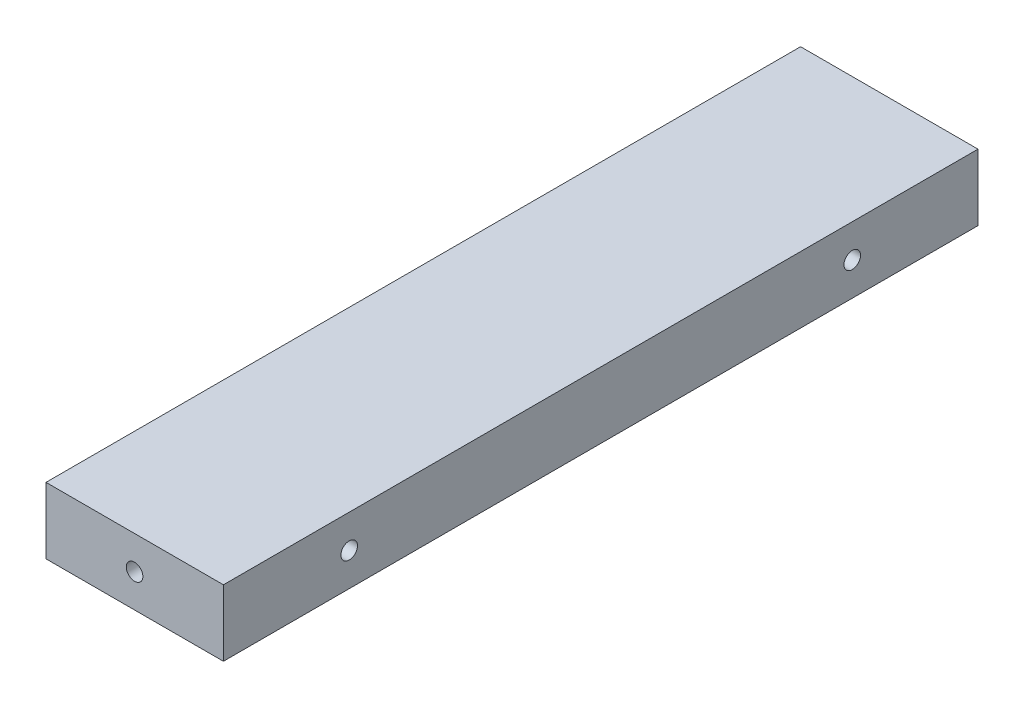
from build123d import *

# Parameters (mm, degrees)
SKETCH1_W           = 34
SKETCH1_H           = 12.7
BOSS_EXTRUDE1_DEPTH = 144.6
HOLE1_D             = 3.175
HOLE1_DEPTH         = 31.75
HOLE1_CSINK_D       = 10.16
HOLE1_CSINK_ANGLE   = 82
HOLE1_TIP           = 0.953866233
HOLE2_D             = 3.175
HOLE2_DEPTH         = 31.75
HOLE2_CSINK_D       = 10.16
HOLE2_CSINK_ANGLE   = 82
HOLE2_TIP           = 0.953866233
HOLE5_D             = 3.175
HOLE5_DEPTH         = 31.75
HOLE5_CSINK_D       = 10.16
HOLE5_CSINK_ANGLE   = 82
HOLE5_TIP           = 0.953866233
HOLE6_D             = 3.175
HOLE6_DEPTH         = 31.75
HOLE6_CSINK_D       = 10.16
HOLE6_CSINK_ANGLE   = 82
HOLE6_TIP           = 0.953866233
HOLE7_D             = 3.175
HOLE7_DEPTH         = 31.75
HOLE7_CSINK_D       = 10.16
HOLE7_CSINK_ANGLE   = 82
HOLE7_TIP           = 0.953866233


with BuildPart() as part:
    # Sketch1 → Boss-Extrude1 (new body)
    with BuildSketch(Plane.XY):
        with Locations((-23.08092085, -126.349999994)):
            Rectangle(SKETCH1_W, SKETCH1_H)
    extrude(amount=BOSS_EXTRUDE1_DEPTH)

    # Hole1
    with Locations(Plane(origin=(12.91907915, 0, 155.024290059), x_dir=(0, -1, 0), z_dir=(1, 0, 0))):
        with Locations((126.349999994, 161.374290059), (146.083333327, 4.074290059), (172.166666661, 4.074290059), (126.349999994, 34.524290059), (126.349999994, 130.924290059), (-172.166666661, 4.074290059), (-146.083333327, 4.074290059), (-126.349999994, 34.524290059), (-126.349999994, 130.924290059), (-126.349999994, 161.374290059)):
            CounterSinkHole(HOLE1_D / 2, HOLE1_CSINK_D / 2, depth=HOLE1_DEPTH, counter_sink_angle=HOLE1_CSINK_ANGLE)
            with Locations((0, 0, -(HOLE1_DEPTH + HOLE1_TIP / 2))):  # 118° drill point
                Cone(0, HOLE1_D / 2, HOLE1_TIP, mode=Mode.SUBTRACT)

    # Hole2
    with Locations(Plane(origin=(12.91907915, 0, -10.424290059), x_dir=(0, 1, 0), z_dir=(1, 0, 0))):
        with Locations((126.349999994, 161.374290059), (146.083333327, 4.074290059), (172.166666661, 4.074290059), (126.349999994, 34.524290059), (126.349999994, 130.924290059), (-172.166666661, 4.074290059), (-146.083333327, 4.074290059), (-126.349999994, 34.524290059), (-126.349999994, 130.924290059), (-126.349999994, 161.374290059)):
            CounterSinkHole(HOLE2_D / 2, HOLE2_CSINK_D / 2, depth=HOLE2_DEPTH, counter_sink_angle=HOLE2_CSINK_ANGLE)
            with Locations((0, 0, -(HOLE2_DEPTH + HOLE2_TIP / 2))):  # 118° drill point
                Cone(0, HOLE2_D / 2, HOLE2_TIP, mode=Mode.SUBTRACT)

    # Hole5
    with Locations(Plane(origin=(-195.367659426, 0, 157.3), x_dir=(0, -1, 0), z_dir=(0, 0, 1))):
        with Locations((207.774999994, 172.261738577), (126.349999994, 172.261738577)):
            CounterSinkHole(HOLE5_D / 2, HOLE5_CSINK_D / 2, depth=HOLE5_DEPTH, counter_sink_angle=HOLE5_CSINK_ANGLE)
            with Locations((0, 0, -(HOLE5_DEPTH + HOLE5_TIP / 2))):  # 118° drill point
                Cone(0, HOLE5_D / 2, HOLE5_TIP, mode=Mode.SUBTRACT)

    # Hole6
    with Locations(Plane(origin=(-52.78092085, 0, -10.424290059), x_dir=(0, -1, 0), z_dir=(-1, 0, 0))):
        with Locations((-207.774999994, 333.02141023), (-207.774999994, 225.48903684), (-207.774999994, 137.424290059), (-172.166666661, 4.074290059), (-146.083333327, 4.074290059), (-94.599999994, 161.374290059), (0, 161.374290059), (94.599999994, 161.374290059), (146.083333327, 4.074290059), (172.166666661, 4.074290059), (207.774999994, 137.424290059), (207.774999994, 225.48903684), (207.774999994, 333.02141023), (166.795833328, 301.970350905), (40.979166666, 301.970350905), (-40.979166666, 301.970350905), (-166.795833328, 301.970350905), (0, 193.124290059), (0, 301.970350905), (0, 412.366411751), (-126.349999994, 106.824290059), (-126.349999994, 58.624290059), (126.349999994, 58.624290059), (126.349999994, 106.824290059)):
            CounterSinkHole(HOLE6_D / 2, HOLE6_CSINK_D / 2, depth=HOLE6_DEPTH, counter_sink_angle=HOLE6_CSINK_ANGLE)
            with Locations((0, 0, -(HOLE6_DEPTH + HOLE6_TIP / 2))):  # 118° drill point
                Cone(0, HOLE6_D / 2, HOLE6_TIP, mode=Mode.SUBTRACT)

    # Hole7
    with Locations(Plane(origin=(-52.78092085, 0, 155.024290059), x_dir=(0, 1, 0), z_dir=(-1, 0, 0))):
        with Locations((-207.774999994, 333.02141023), (-207.774999994, 225.48903684), (-207.774999994, 137.424290059), (-172.166666661, 4.074290059), (-146.083333327, 4.074290059), (-94.599999994, 161.374290059), (0, 161.374290059), (94.599999994, 161.374290059), (146.083333327, 4.074290059), (172.166666661, 4.074290059), (207.774999994, 137.424290059), (207.774999994, 225.48903684), (207.774999994, 333.02141023), (166.795833328, 301.970350905), (40.979166666, 301.970350905), (-40.979166666, 301.970350905), (-166.795833328, 301.970350905), (0, 193.124290059), (0, 301.970350905), (0, 412.366411751), (-126.349999994, 106.824290059), (-126.349999994, 58.624290059), (126.349999994, 58.624290059), (126.349999994, 106.824290059)):
            CounterSinkHole(HOLE7_D / 2, HOLE7_CSINK_D / 2, depth=HOLE7_DEPTH, counter_sink_angle=HOLE7_CSINK_ANGLE)
            with Locations((0, 0, -(HOLE7_DEPTH + HOLE7_TIP / 2))):  # 118° drill point
                Cone(0, HOLE7_D / 2, HOLE7_TIP, mode=Mode.SUBTRACT)


solid = part.part
